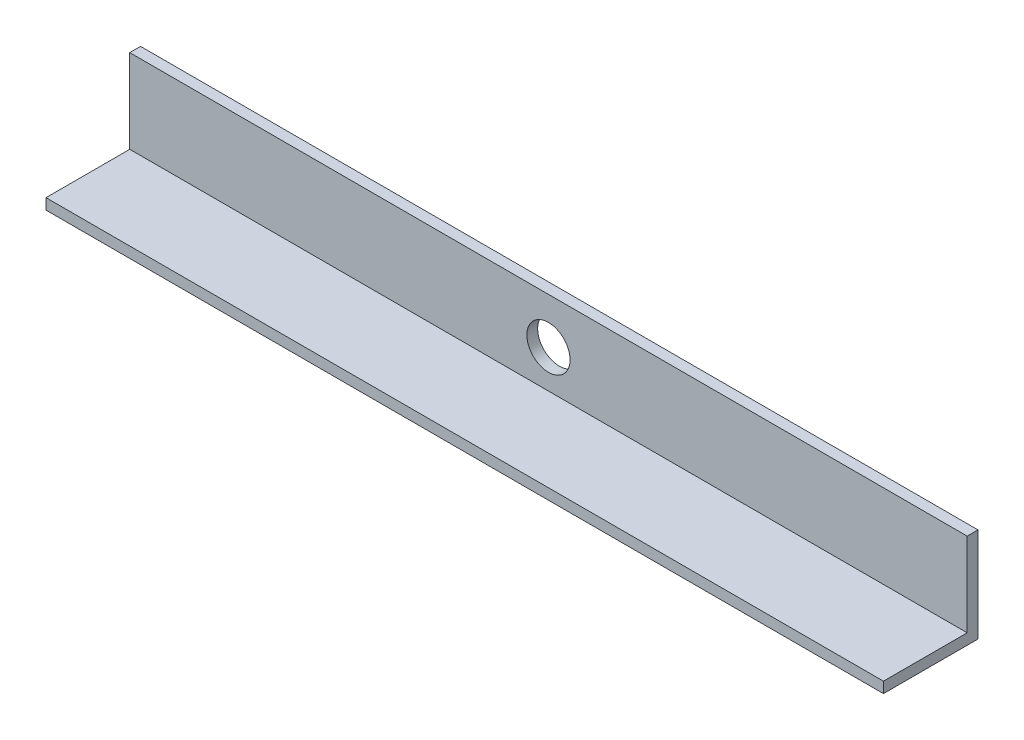
from build123d import *

# Parameters (mm, degrees)
EXTRUDE_1_DEPTH     = 310
SKETCH_2_R          = 8
CUT_EXTRUDE_1_DEPTH = 10


with BuildPart() as part:
    # Эскиз1 → Вытянуть-Тонкостенный1 (new body)
    with BuildSketch(Plane(origin=(0, 0, 0), x_dir=(0, 0, -1), z_dir=(1, 0, 0))):
        Polygon((0, 35), (0, 0), (-35, 0), (-35, 4), (-4, 4), (-4, 35), align=None)
    extrude(amount=EXTRUDE_1_DEPTH)

    # Эскиз2 → Вырез-Вытянуть1 (cut)
    with BuildSketch(Plane(origin=(0, 0, 0), x_dir=(-1, 0, 0), z_dir=(0, 0, -1))):
        with Locations((-155, 18)):
            Circle(SKETCH_2_R)
    extrude(amount=-CUT_EXTRUDE_1_DEPTH, mode=Mode.SUBTRACT)


solid = part.part
